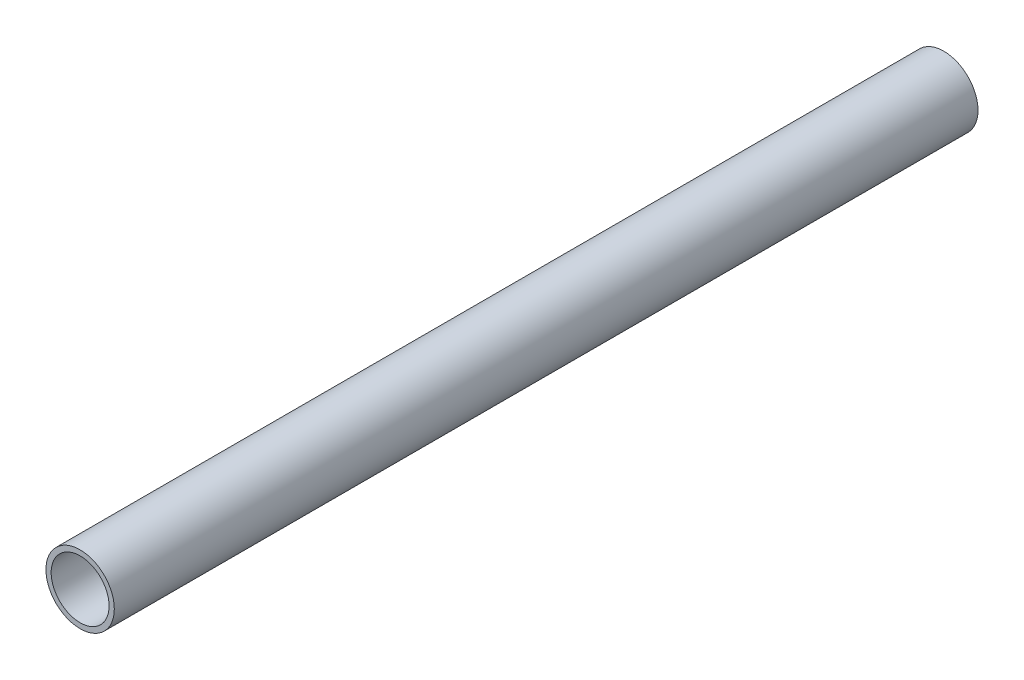
from build123d import *

# Parameters (mm, degrees)
SKETCH1_R           = 24.13
SKETCH1_R_2         = 20.447
EXTRUDE_THIN1_DEPTH = 304.8


with BuildPart() as part:
    # Sketch1 → Extrude-Thin1 (new body, symmetric)
    with BuildSketch(Plane.XY):
        Circle(SKETCH1_R)
        Circle(SKETCH1_R_2, mode=Mode.SUBTRACT)
    extrude(amount=EXTRUDE_THIN1_DEPTH, both=True)


solid = part.part
